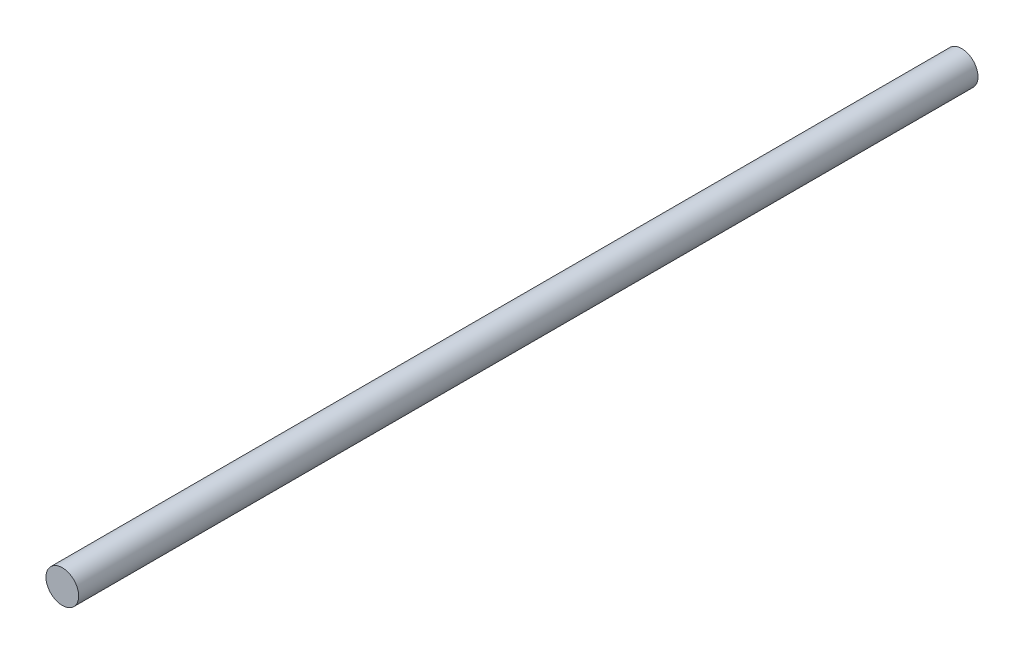
from build123d import *

# Parameters (mm, degrees)
SKETCH1_R           = 3
BOSS_EXTRUDE1_DEPTH = 165


with BuildPart() as part:
    # Sketch1 → Boss-Extrude1 (new body)
    with BuildSketch(Plane.XY):
        Circle(SKETCH1_R)
    extrude(amount=BOSS_EXTRUDE1_DEPTH)


solid = part.part
